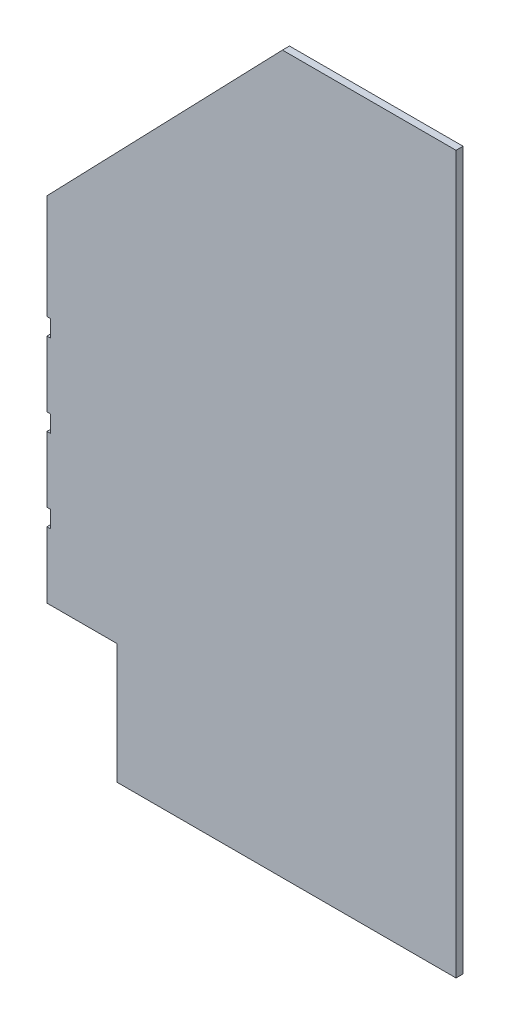
from build123d import *

# Parameters (mm, degrees)
BOSS_EXTRUDE1_DEPTH = 11.90625
SKETCH2_W           = 6.35
SKETCH2_H           = 28.575
CUT_EXTRUDE1_DEPTH  = 12.90625


with BuildPart() as part:
    # Sketch1 → Boss-Extrude1 (new body)
    with BuildSketch(Plane.XY):
        Polygon((-284.234659091, -116.031818182), (-284.234659091, -712.931818182), (-165.965909091, -712.931818182), (-165.965909091, -916.131818182), (407.915340909, -916.131818182), (407.915340909, 296.718181818), (114.227840909, 296.718181818), align=None)
    extrude(amount=BOSS_EXTRUDE1_DEPTH)

    # Sketch2 → Cut-Extrude1 (cut, through all)
    with BuildSketch(Plane.XY.offset(11.90625)):
        with Locations((-281.059659091, -586.693818182)):
            Rectangle(SKETCH2_W, SKETCH2_H)
        with Locations((-281.059659091, -446.993818182)):
            Rectangle(SKETCH2_W, SKETCH2_H)
        with Locations((-281.059659091, -307.293818182)):
            Rectangle(SKETCH2_W, SKETCH2_H)
    extrude(amount=-CUT_EXTRUDE1_DEPTH, mode=Mode.SUBTRACT)


solid = part.part
